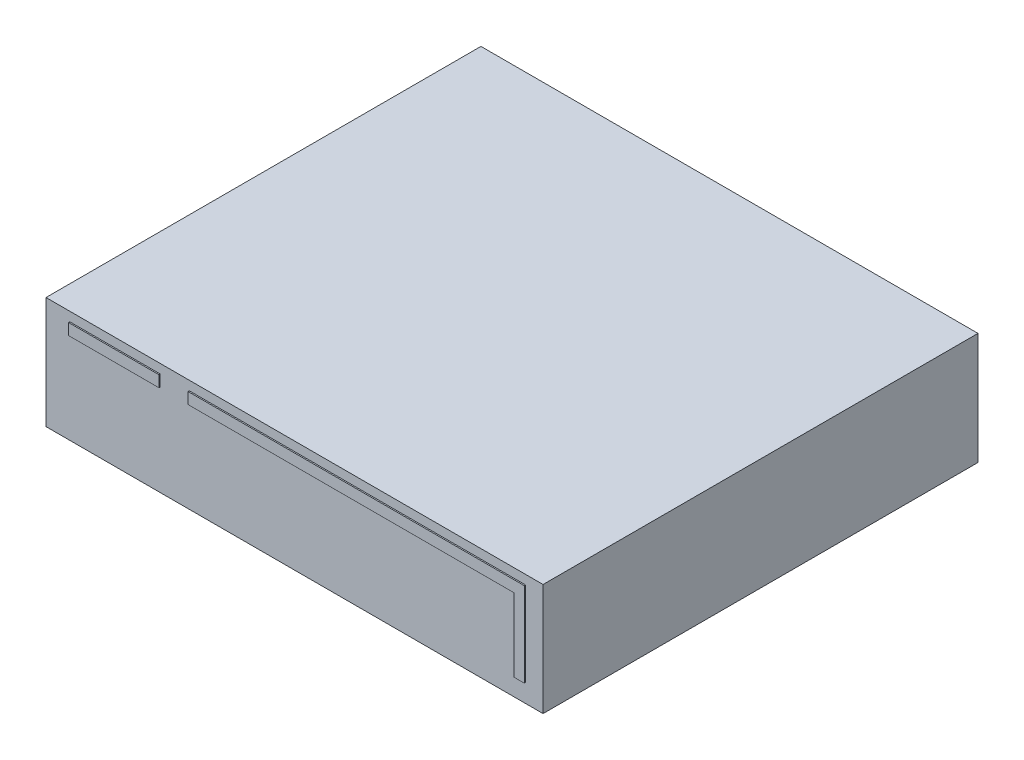
from build123d import *

# Parameters (mm, degrees)
CROQUIS1_W              = 400
CROQUIS1_H              = 90
SALIENTE_EXTRUIR1_DEPTH = 350
CROQUIS2_W              = 72.65553302
CROQUIS2_H              = 9.081941628
SALIENTE_EXTRUIR2_DEPTH = 1


with BuildPart() as part:
    # Croquis1 → Saliente-Extruir1 (new body)
    with BuildSketch(Plane.XY):
        Rectangle(CROQUIS1_W, CROQUIS1_H)
    extrude(amount=-SALIENTE_EXTRUIR1_DEPTH)

    # Croquis2 → Saliente-Extruir2 (add)
    with BuildSketch(Plane.XY):
        with Locations((-144.446119219, 33.084215929)):
            Rectangle(CROQUIS2_W, CROQUIS2_H)
        Polygon((-84.764788524, 37.625186743), (185.963566659, 37.625186743), (185.963566659, 28.543245115), (185.963566659, -30.333468212), (177.50333461, -30.333468212), (177.50333461, 28.543245115), (-84.764788524, 28.543245115), align=None)
    extrude(amount=SALIENTE_EXTRUIR2_DEPTH)


solid = part.part
